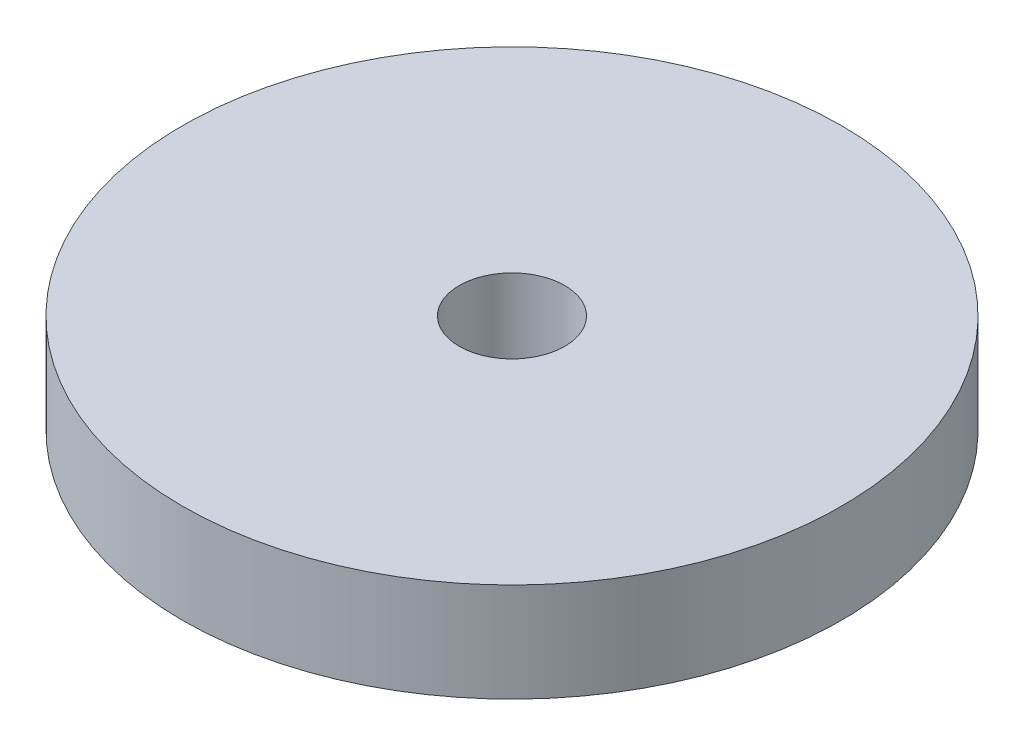
from build123d import *

# Parameters (mm, degrees)
SKETCH1_R           = 10
SKETCH1_R_2         = 1.6
BOSS_EXTRUDE1_DEPTH = 3


with BuildPart() as part:
    # Sketch1 → Boss-Extrude1 (new body)
    with BuildSketch(Plane(origin=(0, 0, 0), x_dir=(1, 0, 0), z_dir=(0, 1, 0))):
        Circle(SKETCH1_R)
        Circle(SKETCH1_R_2, mode=Mode.SUBTRACT)
    extrude(amount=BOSS_EXTRUDE1_DEPTH)


solid = part.part
